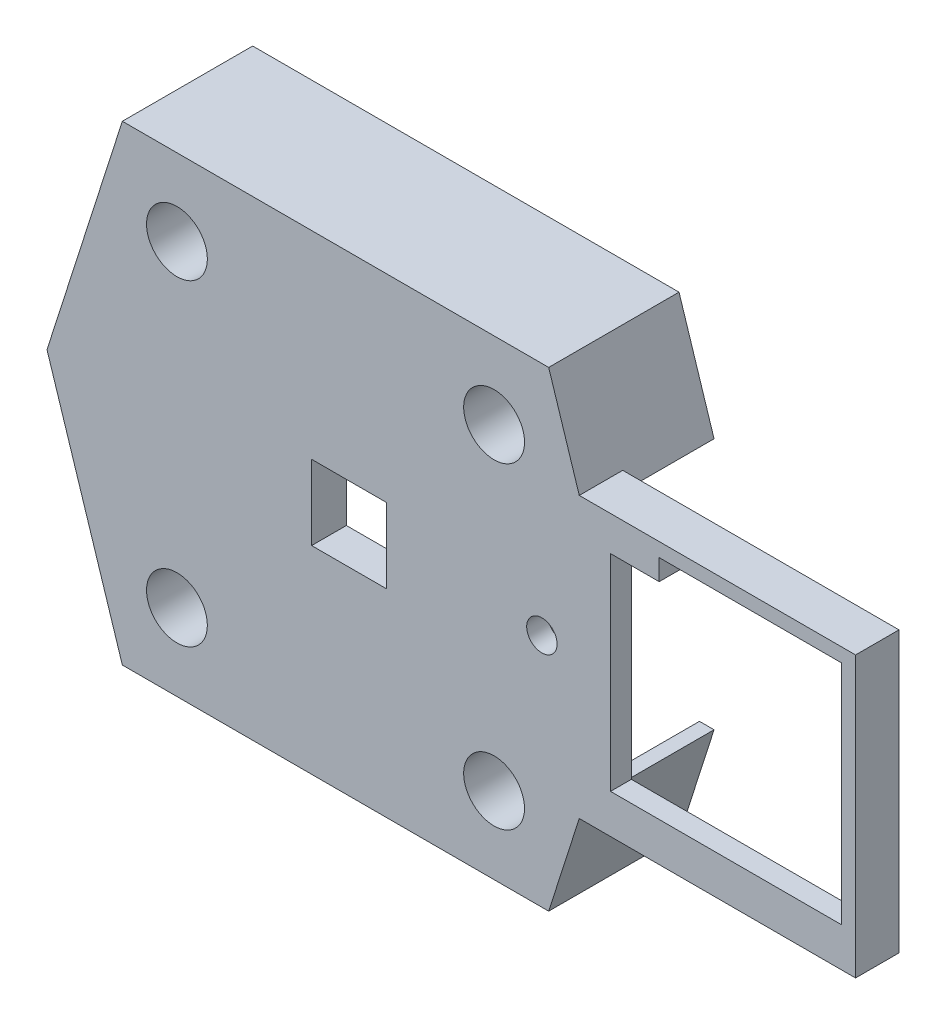
from build123d import *

# Parameters (mm, degrees)
BOSS_EXTRUDE1_DEPTH      = 10
BOSS_EXTRUDE1_DEPTH_BACK = 5
BOSS_EXTRUDE2_DEPTH      = 5
CUT_EXTRUDE1_DEPTH       = 68.390151358
BOSS_EXTRUDE3_DEPTH      = 4
SKETCH7_R                = 1.75
BOSS_EXTRUDE4_DEPTH      = 2.4
SKETCH8_R                = 3.5
BOSS_EXTRUDE5_DEPTH      = 1
SKETCH9_R                = 5.1
SKETCH9_R_2              = 3.5
BOSS_EXTRUDE6_DEPTH      = 9


with BuildPart() as part:
    # Sketch2 → Boss-Extrude1 (new, two sides)
    with BuildSketch(Plane.XY.offset(12)) as boss_extrude1_sk:
        Polygon((-24.532899998, 27.1), (-33.204899998, 0), (-24.532899998, -27.1), (24.532899998, -27.1), (33.204899998, 0), (24.532899998, 27.1), align=None)
        Polygon((-23.36497619, 25.5), (-31.52497619, 0), (-23.36497619, -25.5), (23.36497619, -25.5), (31.52497619, 0), (23.36497619, 25.5), align=None, mode=Mode.SUBTRACT)
    extrude(amount=BOSS_EXTRUDE1_DEPTH)
    extrude(boss_extrude1_sk.sketch, amount=-BOSS_EXTRUDE1_DEPTH_BACK)

    # Sketch3 → Boss-Extrude2 (add)
    with BuildSketch(Plane.XY.offset(22)):
        Polygon((29.75, 16.1), (59.85, 16.1), (59.85, -16.1), (29.75, -16.1), (28.052899998, -16.1), (28.564899998, -14.5), (29.75, -14.5), (58.25, -14.5), (58.25, 14.5), (29.75, 14.5), (28.564899998, 14.5), (28.052899998, 16.1), align=None)
    extrude(amount=-BOSS_EXTRUDE2_DEPTH)

    # Sketch4 → Cut-Extrude1 (cut, through all)
    with BuildSketch(Plane(origin=(0, 0, 7), x_dir=(-1, 0, 0), z_dir=(0, 0, -1))):
        Polygon((-26.88497619, 14.5), (-28.564899998, 14.5), (-33.204899998, 0), (-28.564899998, -14.5), (-26.88497619, -14.5), (-31.52497619, 0), align=None)
    extrude(amount=-CUT_EXTRUDE1_DEPTH, mode=Mode.SUBTRACT)

    # Sketch5 → Boss-Extrude3 (add)
    with BuildSketch(Plane.XY.offset(22)):
        Polygon((29.25, 4.3), (29.25, 14), (29.25, 14.5), (27.65, 14.5), (27.65, 14), (27.65, 5.9), (-4.35, 5.9), (-4.35, -5.9), (27.65, -5.9), (27.65, -14), (27.65, -14.5), (29.25, -14.5), (29.25, -14), (29.25, -4.3), (-2.75, -4.3), (-2.75, 4.3), align=None)
    extrude(amount=-BOSS_EXTRUDE3_DEPTH)

    # Sketch7 → Boss-Extrude4 (add)
    with BuildSketch(Plane.XY.offset(22)):
        Polygon((37.25, 12.1), (37.25, 14.5), (29.25, 14.5), (29.25, 4.3), (5.85, 4.3), (5.85, -4.3), (29.25, -4.3), (29.25, -14.5), (58.25, -14.5), (58.25, -11.6), (31.65, -11.6), (31.65, 12.1), align=None)
        with Locations((23.75, 0)):
            Circle(SKETCH7_R, mode=Mode.SUBTRACT)
    extrude(amount=-BOSS_EXTRUDE4_DEPTH)

    # Sketch8 → Boss-Extrude5 (add)
    with BuildSketch(Plane.XY.offset(22)):
        Polygon((27.65, -5.9), (27.65, -14.5), (26.88497619, -14.5), (23.36497619, -25.5), (-23.36497619, -25.5), (-31.52497619, 0), (-23.36497619, 25.5), (23.36497619, 25.5), (26.88497619, 14.5), (27.65, 14.5), (27.65, 5.9), (-4.35, 5.9), (-4.35, -5.9), align=None)
        with Locations((-18.25, 18.25)):
            Circle(SKETCH8_R, mode=Mode.SUBTRACT)
        with Locations((18.25, 18.25)):
            Circle(SKETCH8_R, mode=Mode.SUBTRACT)
        with Locations((18.25, -18.25)):
            Circle(SKETCH8_R, mode=Mode.SUBTRACT)
        with Locations((-18.25, -18.25)):
            Circle(SKETCH8_R, mode=Mode.SUBTRACT)
    extrude(amount=-BOSS_EXTRUDE5_DEPTH)

    # Sketch9 → Boss-Extrude6 (add)
    with BuildSketch(Plane(origin=(0, 0, 21), x_dir=(-1, 0, 0), z_dir=(0, 0, -1))):
        with Locations(Location((-18.25, 18.25, 0), (0, 0, 180))):
            Circle(SKETCH9_R)
        with Locations(Location((-18.25, 18.25, 0), (0, 0, 180))):
            Circle(SKETCH9_R_2, mode=Mode.SUBTRACT)
        with Locations(Location((18.25, 18.25, 0), (0, 0, 180))):
            Circle(SKETCH9_R)
        with Locations(Location((18.25, 18.25, 0), (0, 0, 180))):
            Circle(SKETCH9_R_2, mode=Mode.SUBTRACT)
        with Locations(Location((18.25, -18.25, 0), (0, 0, 180))):
            Circle(SKETCH9_R)
        with Locations(Location((18.25, -18.25, 0), (0, 0, 180))):
            Circle(SKETCH9_R_2, mode=Mode.SUBTRACT)
        with Locations(Location((-18.25, -18.25, 0), (0, 0, 180))):
            Circle(SKETCH9_R)
        with Locations(Location((-18.25, -18.25, 0), (0, 0, 180))):
            Circle(SKETCH9_R_2, mode=Mode.SUBTRACT)
    extrude(amount=BOSS_EXTRUDE6_DEPTH)


solid = part.part
